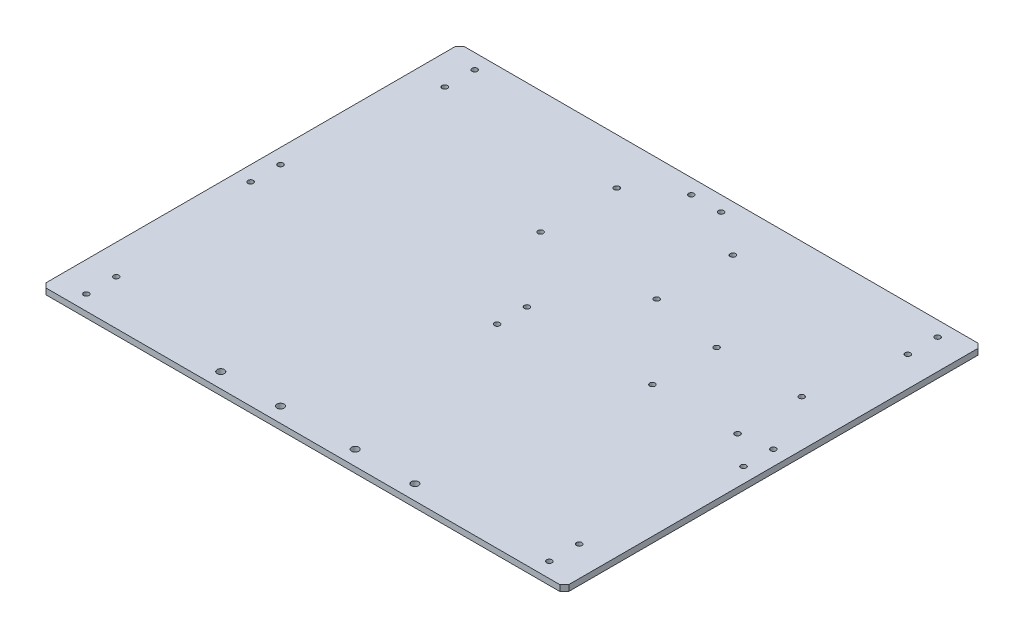
from build123d import *

# Parameters (mm, degrees)
SKIZZE1_W                       = 350
SKIZZE1_H                       = 280
SKIZZE1_R                       = 1.8
AUFSATZ_LINEAR_AUSTRAGEN1_DEPTH = 4
FASE1_SIZE                      = 3
DURCHGANGSLOCH_F_R_M31_D        = 3.6
SPIEGELN2_COPY_1_D              = 3.6
DURCHGANGSLOCH_F_R_M32_D        = 3.6
DURCHGANGSLOCH_F_R_M42_D        = 4.8
DURCHGANGSLOCH_F_R_M34_D        = 3.6


with BuildPart() as part:
    # Skizze1 → Aufsatz-Linear austragen1 (new body)
    with BuildSketch(Plane(origin=(0, 0, 0), x_dir=(1, 0, 0), z_dir=(0, 1, 0))):
        Rectangle(SKIZZE1_W, SKIZZE1_H)
        with Locations((-38.875, 109)):
            Circle(SKIZZE1_R, mode=Mode.SUBTRACT)
        with Locations((-38.875, 58)):
            Circle(SKIZZE1_R, mode=Mode.SUBTRACT)
        with Locations((38.875, 109)):
            Circle(SKIZZE1_R, mode=Mode.SUBTRACT)
        with Locations((38.875, 58)):
            Circle(SKIZZE1_R, mode=Mode.SUBTRACT)
        with Locations((87, 50)):
            Circle(SKIZZE1_R, mode=Mode.SUBTRACT)
        with Locations((87, 7)):
            Circle(SKIZZE1_R, mode=Mode.SUBTRACT)
        with Locations((144, 7)):
            Circle(SKIZZE1_R, mode=Mode.SUBTRACT)
        with Locations((144, 50)):
            Circle(SKIZZE1_R, mode=Mode.SUBTRACT)
    extrude(amount=AUFSATZ_LINEAR_AUSTRAGEN1_DEPTH)

    # Fase1
    fase1_edges = [part.edges().sort_by_distance(p)[0] for p in [
        (-175, 2, -140),
        (175, 2, -140),
        (175, 2, 140),
        (-175, 2, 140),
    ]]
    chamfer(fase1_edges, length=FASE1_SIZE)

    # Durchgangsloch für M31 (through all)
    with Locations(Plane(origin=(0, 4, 0), x_dir=(1, 0, 0), z_dir=(0, 1, 0))):
        with Locations((-155, 130), (-155, 110)):
            durchgangsloch_f_r_m31 = Hole(DURCHGANGSLOCH_F_R_M31_D / 2)

    # Spiegeln1: Durchgangsloch für M31 across plane
    add(durchgangsloch_f_r_m31.mirror(Plane(origin=(0, 0, 0), x_dir=(0, 0, 1), z_dir=(1, 0, 0))), mode=Mode.SUBTRACT)

    # Spiegeln2: Durchgangsloch für M31 across plane
    add(durchgangsloch_f_r_m31.mirror(Plane.XY), mode=Mode.SUBTRACT)

    # Spiegeln2 copy 1 (through all)
    with Locations(Plane(origin=(0, 4, 0), x_dir=(-1, 0, 0), z_dir=(0, 1, 0))):
        with Locations((-155, 130), (-155, 110)):
            Hole(SPIEGELN2_COPY_1_D / 2)

    # Durchgangsloch für M32 (through all)
    with Locations(Plane(origin=(0, 4, 0), x_dir=(1, 0, 0), z_dir=(0, 1, 0))):
        with Locations((0, 10), (0, -10)):
            Hole(DURCHGANGSLOCH_F_R_M32_D / 2)

    # Durchgangsloch für M42 (through all)
    with Locations(Plane(origin=(0, 4, 0), x_dir=(1, 0, 0), z_dir=(0, 1, 0))):
        with Locations((-65, -130), (-25, -130), (25, -130), (65, -130)):
            Hole(DURCHGANGSLOCH_F_R_M42_D / 2)

    # Durchgangsloch für M34 (through all)
    with Locations(Plane(origin=(0, 4, 0), x_dir=(1, 0, 0), z_dir=(0, 1, 0))):
        with Locations((-165, 10), (-165, -10), (-10, 130)):
            durchgangsloch_f_r_m34 = Hole(DURCHGANGSLOCH_F_R_M34_D / 2)

    # Spiegeln3: Durchgangsloch für M34 across plane
    add(durchgangsloch_f_r_m34.mirror(Plane(origin=(0, 0, 0), x_dir=(0, 0, 1), z_dir=(1, 0, 0))), mode=Mode.SUBTRACT)


solid = part.part
